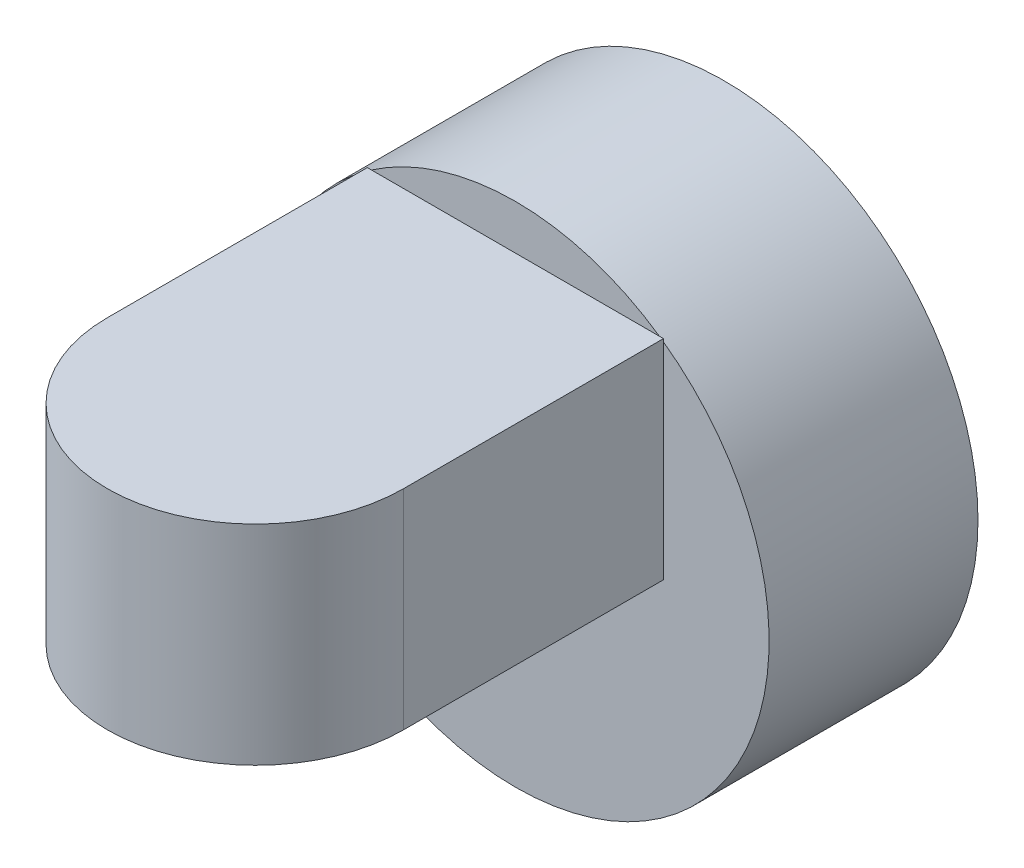
from build123d import *

# Parameters (mm, degrees)
SKETCH1_R           = 12.85
BOSS_EXTRUDE5_DEPTH = 10.58
SKETCH4_R           = 7.5
SKETCH4_R_2         = 4.5
BOSS_EXTRUDE6_DEPTH = 10.58


with BuildPart() as part:
    # Sketch1 → Boss-Extrude5 (new body)
    with BuildSketch(Plane.XY):
        Circle(SKETCH1_R)
    extrude(amount=BOSS_EXTRUDE5_DEPTH)

    # Sketch4 → Boss-Extrude6 (add)
    with BuildSketch(Plane(origin=(0, 0, 0), x_dir=(1, 0, 0), z_dir=(0, 1, 0))):
        with BuildLine():
            Line((-7.5, -10.58), (-7.5, -23.749253103))
            ThreePointArc((-7.5, -23.749253103), (0, -16.249253103), (7.5, -23.749253103))
            Line((7.5, -23.749253103), (7.5, -10.58))
            Line((7.5, -10.58), (-7.5, -10.58))
        make_face()
        with Locations((0, -23.749253103)):
            Circle(SKETCH4_R)
        with Locations((0, -23.749253103)):
            Circle(SKETCH4_R_2, mode=Mode.SUBTRACT)
        with Locations((0, -23.749253103)):
            Circle(SKETCH4_R_2)
    extrude(amount=BOSS_EXTRUDE6_DEPTH)


solid = part.part
